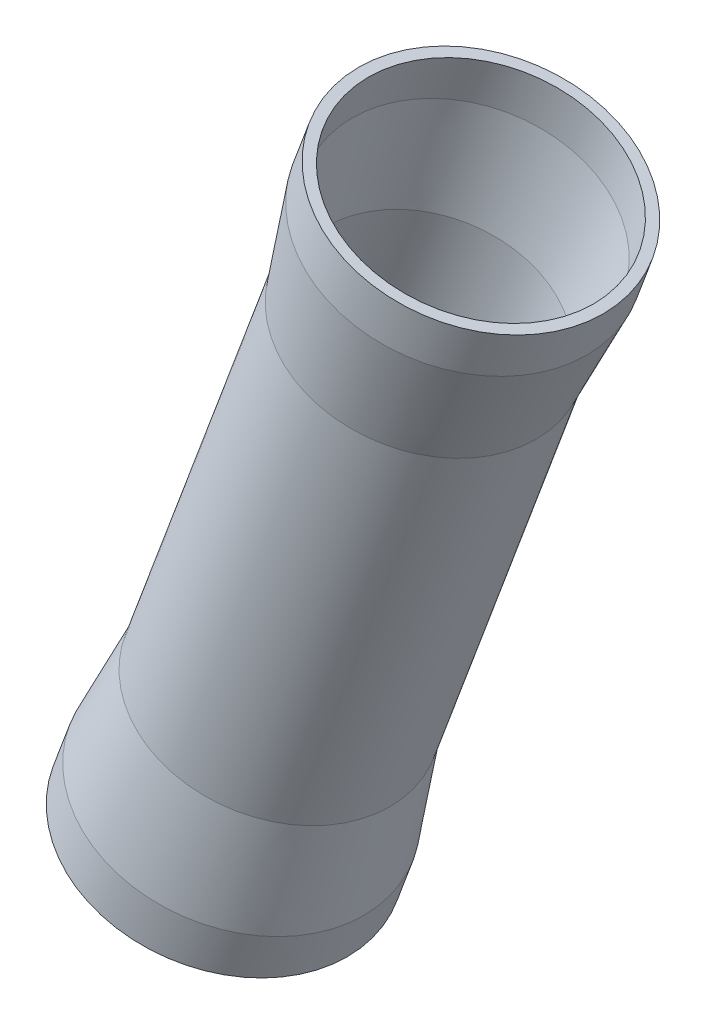
from build123d import *

# Parameters (mm, degrees)
COQUE1_T = -2


with BuildPart() as part:
    # Esquisse2 → Révolution1 (revolve)
    with BuildSketch(Plane.XY, mode=Mode.PRIVATE) as r_volution1_sk:
        Polygon((-393.705721225, 604.708824353), (-370.2870475, 595.9586403), (-419.288078193, 464.814067439), (-442.706751918, 473.564251491), (-439.55668566, 481.994974032), (-429.864663683, 500.791641556), (-401.864074716, 575.731397477), (-396.855787484, 596.278101812), align=None)
    revolve(r_volution1_sk.sketch.rotate(Axis((-437.599068934, 415.807199106, 0), (0.350007362, 0.936746949, 0)), 180), axis=Axis((-437.599068934, 415.807199106, 0), (0.350007362, 0.936746949, 0)))  # turned: the seam where the file's is

    # Coque1
    coque1_openings = [part.faces().sort_by_distance(p)[0] for p in [
        (-370.2870475, 595.9586403, 0),
        (-419.288078193, 464.814067439, 0),
    ]]
    offset(amount=COQUE1_T, openings=coque1_openings, kind=Kind.INTERSECTION)


solid = part.part
